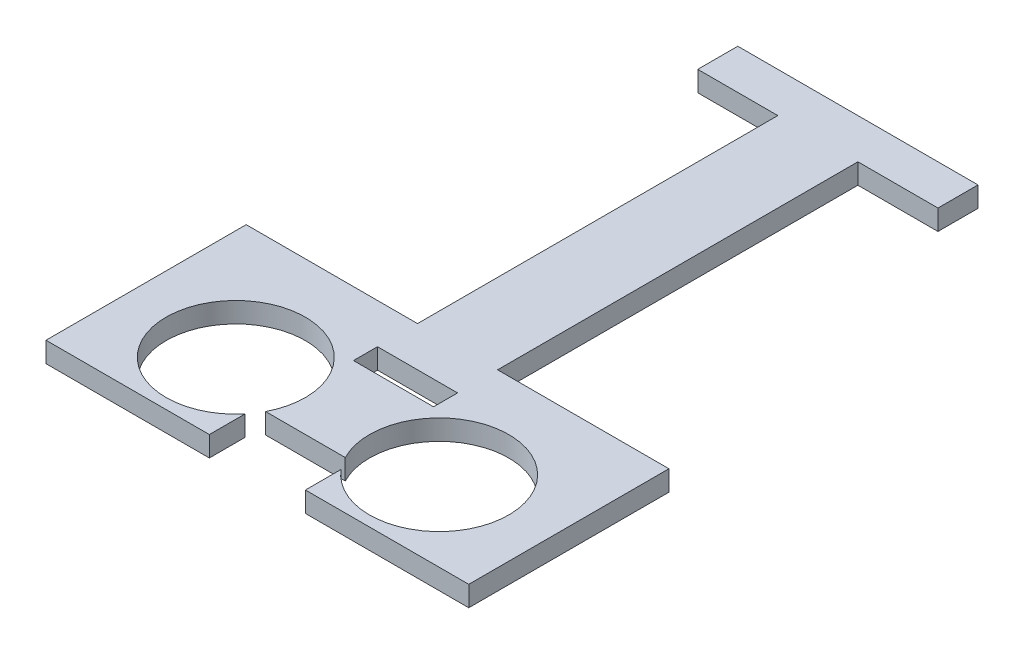
from build123d import *

# Parameters (mm, degrees)
SKETCH1_W           = 10
SKETCH1_H           = 3
BOSS_EXTRUDE2_DEPTH = 2.54


with BuildPart() as part:
    # Sketch1 → Boss-Extrude2 (new body)
    with BuildSketch(Plane(origin=(0, 0, 0), x_dir=(1, 0, 0), z_dir=(0, 1, 0))):
        with BuildLine():
            Line((-12.751841201, 24.899770263), (-2.751841201, 24.899770263))
            Line((-2.751841201, 24.899770263), (-2.751841201, -20.100229737))
            Line((-2.751841201, -20.100229737), (-24.151841201, -20.100229737))
            Line((-24.151841201, -20.100229737), (-24.151841201, -45.100229737))
            Line((-24.151841201, -45.100229737), (-3.751841201, -45.100229737))
            Line((-3.751841201, -45.100229737), (-3.751841201, -40.650004508))
            ThreePointArc((-3.751841201, -40.650004508), (-17.706309974, -30.297867525), (-2.725910836, -39.100229737))
            Line((-2.725910836, -39.100229737), (7.222228435, -39.100229737))
            ThreePointArc((7.222228435, -39.100229737), (22.202627573, -30.297867525), (8.248158799, -40.650004508))
            Line((8.248158799, -40.650004508), (8.248158799, -45.100229737))
            Line((8.248158799, -45.100229737), (28.648158799, -45.100229737))
            Line((28.648158799, -45.100229737), (28.648158799, -20.100229737))
            Line((28.648158799, -20.100229737), (7.248158799, -20.100229737))
            Line((7.248158799, -20.100229737), (7.248158799, 24.899770263))
            Line((7.248158799, 24.899770263), (17.248158799, 24.899770263))
            Line((17.248158799, 24.899770263), (17.248158799, 29.899770263))
            Line((17.248158799, 29.899770263), (-12.751841201, 29.899770263))
            Line((-12.751841201, 29.899770263), (-12.751841201, 24.899770263))
        make_face()
        with Locations((2.248158799, -26.600229737)):
            Rectangle(SKETCH1_W, SKETCH1_H, mode=Mode.SUBTRACT)
    extrude(amount=BOSS_EXTRUDE2_DEPTH)


solid = part.part
